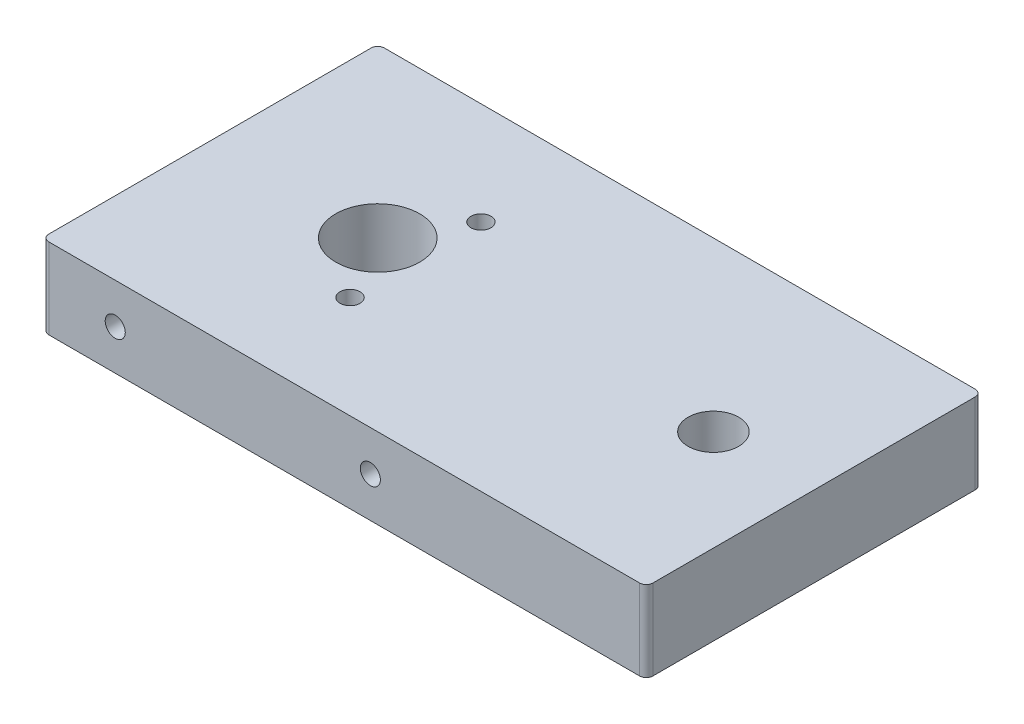
from build123d import *

# Parameters (mm, degrees)
SKETCH1_W                                            = 114.3
SKETCH1_H                                            = 63.5
BOSS_EXTRUDE1_DEPTH                                  = 15.24
F_5_8_0_625_DIAMETER_HOLE1_D                         = 15.875
F_10_24_TAPPED_HOLE3_D                               = 3.7973
CBORE_FOR_3_8_BINDING_HEAD_MACHINE_SCREW_D           = 9.5758
CBORE_FOR_3_8_BINDING_HEAD_MACHINE_SCREW_CBORE_D     = 19.05
CBORE_FOR_3_8_BINDING_HEAD_MACHINE_SCREW_CBORE_DEPTH = 7.62
F_10_24_TAPPED_HOLE1_D                               = 3.7973
F_10_24_TAPPED_HOLE1_DEPTH                           = 10.035175986
F_10_24_TAPPED_HOLE1_TIP                             = 1.140824014
F_10_24_TAPPED_HOLE2_D                               = 3.7973
F_10_24_TAPPED_HOLE2_DEPTH                           = 10.035175986
F_10_24_TAPPED_HOLE2_TIP                             = 1.140824014
FILLET1_R                                            = 1.27


with BuildPart() as part:
    # Sketch1 → Boss-Extrude1 (new body)
    with BuildSketch(Plane(origin=(0, 0, 0), x_dir=(1, 0, 0), z_dir=(0, 1, 0))):
        with Locations((-6.35, 0)):
            Rectangle(SKETCH1_W, SKETCH1_H)
    extrude(amount=BOSS_EXTRUDE1_DEPTH)

    # 5/8 (0.625) Diameter Hole1 (through all)
    with Locations(Plane(origin=(0, 15.24, 0), x_dir=(1, 0, 0), z_dir=(0, 1, 0))):
        with Locations((-31.75, 0)):
            Hole(F_5_8_0_625_DIAMETER_HOLE1_D / 2)

    # #10-24 Tapped Hole3 (through all)
    with Locations(Plane(origin=(0, 15.24, 0), x_dir=(1, 0, 0), z_dir=(0, 1, 0))):
        with Locations((-24.60625, -12.373337957), (-24.60625, 12.373337957)):
            Hole(F_10_24_TAPPED_HOLE3_D / 2)

    # CBORE for 3/8 Binding Head Machine Screw1 (through all)
    with Locations(Plane(origin=(0, 0, 0), x_dir=(-1, 0, 0), z_dir=(0, -1, 0))):
        with Locations((-31.75, 0)):
            CounterBoreHole(CBORE_FOR_3_8_BINDING_HEAD_MACHINE_SCREW_D / 2, CBORE_FOR_3_8_BINDING_HEAD_MACHINE_SCREW_CBORE_D / 2, CBORE_FOR_3_8_BINDING_HEAD_MACHINE_SCREW_CBORE_DEPTH)

    # #10-24 Tapped Hole1
    with Locations(Plane(origin=(0, 0, -31.75), x_dir=(-1, 0, 0), z_dir=(0, 0, -1))):
        with Locations((49.657, 7.62), (1.397, 7.62)):
            Hole(F_10_24_TAPPED_HOLE1_D / 2, depth=F_10_24_TAPPED_HOLE1_DEPTH)
            with Locations((0, 0, -(F_10_24_TAPPED_HOLE1_DEPTH + F_10_24_TAPPED_HOLE1_TIP / 2))):  # 118° drill point
                Cone(0, F_10_24_TAPPED_HOLE1_D / 2, F_10_24_TAPPED_HOLE1_TIP, mode=Mode.SUBTRACT)

    # #10-24 Tapped Hole2
    with Locations(Plane.XY.offset(31.75)):
        with Locations((-49.657, 7.62), (-1.397, 7.62)):
            Hole(F_10_24_TAPPED_HOLE2_D / 2, depth=F_10_24_TAPPED_HOLE2_DEPTH)
            with Locations((0, 0, -(F_10_24_TAPPED_HOLE2_DEPTH + F_10_24_TAPPED_HOLE2_TIP / 2))):  # 118° drill point
                Cone(0, F_10_24_TAPPED_HOLE2_D / 2, F_10_24_TAPPED_HOLE2_TIP, mode=Mode.SUBTRACT)

    # Fillet1
    fillet1_edges = [part.edges().sort_by_distance(p)[0] for p in [
        (50.8, 7.62, -31.75),
        (-63.5, 7.62, -31.75),
        (-63.5, 7.62, 31.75),
        (50.8, 7.62, 31.75),
    ]]
    fillet(fillet1_edges, radius=FILLET1_R)


solid = part.part
